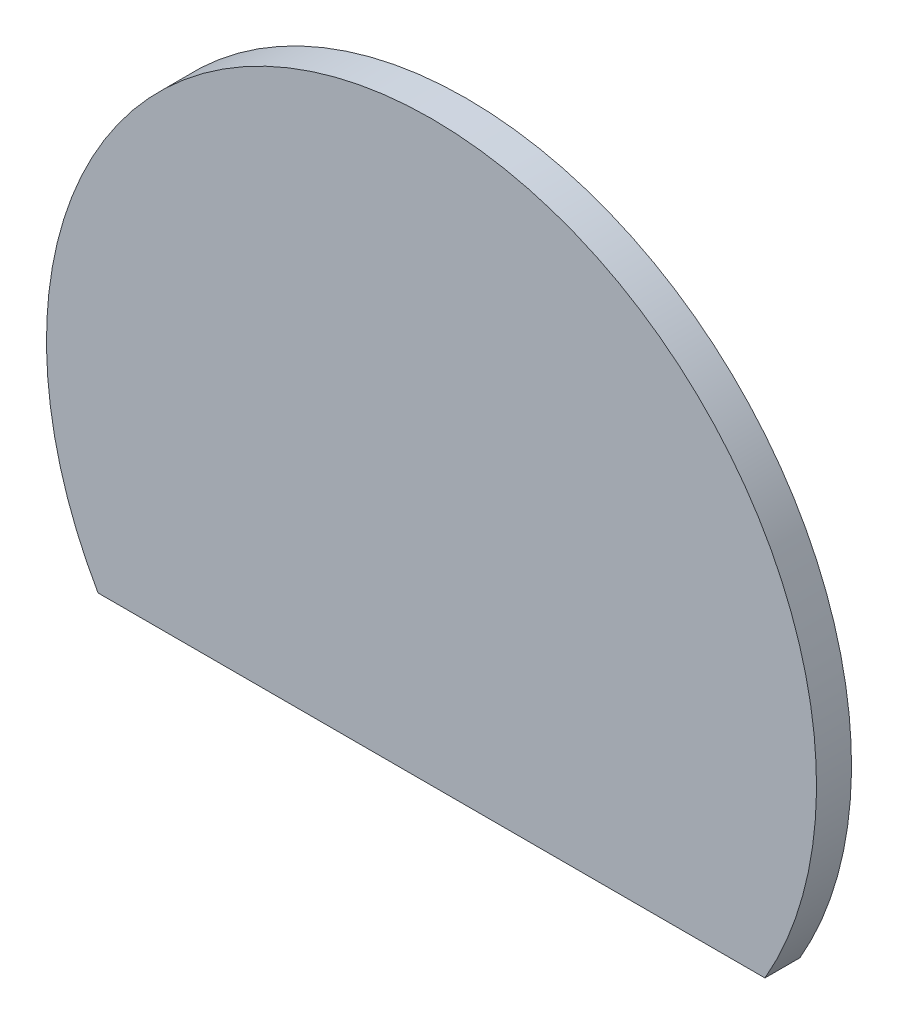
from build123d import *

# Parameters (mm, degrees)
BOSS_EXTRUDE1_DEPTH = 1
SKETCH3_R           = 4.5
SKETCH3_R_2         = 3.5
BOSS_EXTRUDE2_DEPTH = 2.2
SKETCH4_R           = 1.4
BOSS_EXTRUDE3_DEPTH = 3


with BuildPart() as part:
    # Sketch1 → Boss-Extrude1 (new body)
    with BuildSketch(Plane.XY):
        with BuildLine():
            Line((-9.526279442, -5.5), (9.526279442, -5.5))
            ThreePointArc((9.526279442, -5.5), (0, 11), (-9.526279442, -5.5))
        make_face()
    extrude(amount=BOSS_EXTRUDE1_DEPTH)

    # Sketch3 → Boss-Extrude2 (add)
    with BuildSketch(Plane(origin=(0, 0, 0), x_dir=(-1, 0, 0), z_dir=(0, 0, -1))):
        Circle(SKETCH3_R)
        Circle(SKETCH3_R_2, mode=Mode.SUBTRACT)
    extrude(amount=BOSS_EXTRUDE2_DEPTH)

    # Sketch4 → Boss-Extrude3 (add)
    with BuildSketch(Plane(origin=(0, 0, 0), x_dir=(-1, 0, 0), z_dir=(0, 0, -1))):
        Circle(SKETCH4_R)
    extrude(amount=BOSS_EXTRUDE3_DEPTH)


solid = part.part
